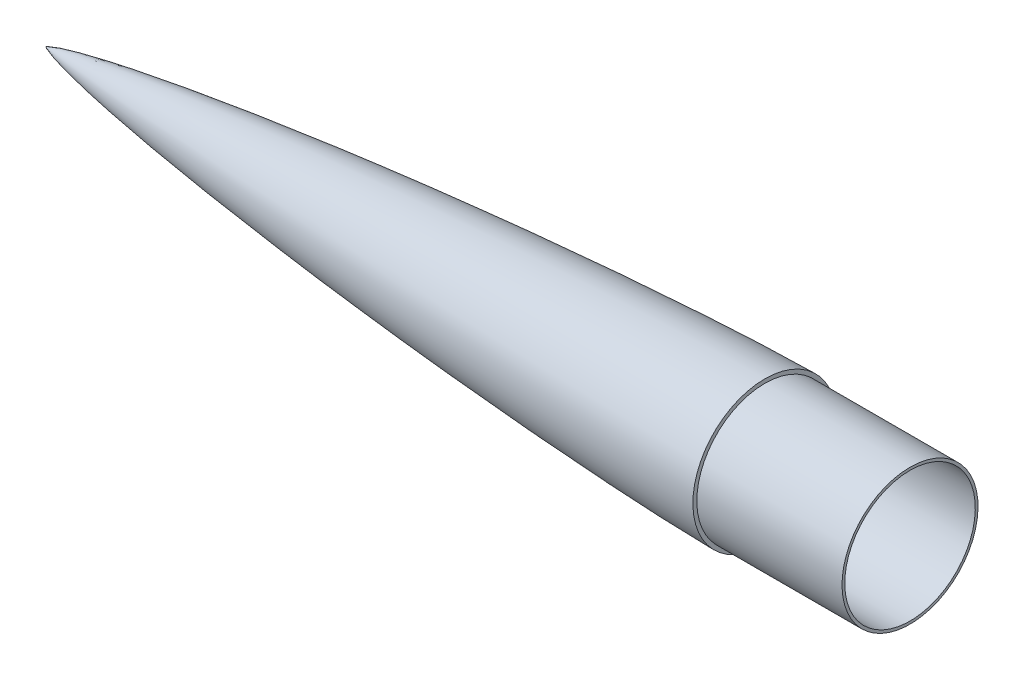
from build123d import *


with BuildPart() as part:
    # Sketch1 → Revolve1 (revolve)
    with BuildSketch(Plane.XY):
        with BuildLine():
            Line((-144.476509098, 35.965), (0, 35.965))
            Line((0, 35.965), (0, 37.465))
            Line((0, 37.465), (-80, 37.465))
            Line((-80, 37.465), (-80, 39.624))
            add(Edge.make_bspline(
                [(-476, 0), (-475.999922921, 0.000860537), (-475.991878272, 0.019203374), (-475.965540019, 0.048886411), (-475.880792524, 0.123460292), (-475.734454888, 0.21905445), (-475.487969376, 0.357045715), (-474.9464108, 0.615798146), (-473.651617124, 1.129793495), (-471.290217835, 1.8875051), (-467.913404676, 2.808553244), (-463.576468666, 3.851264331), (-458.798752951, 4.896132034), (-452.589553113, 6.156031899), (-444.698966637, 7.630967891), (-435.267626096, 9.257539518), (-421.488450856, 11.458403108), (-404.627471312, 13.926156523), (-384.923327778, 16.569178409), (-362.372449265, 19.340500799), (-339.797340005, 21.905895469), (-317.202600234, 24.291785719), (-294.591354976, 26.515336789), (-271.965726929, 28.587274182), (-249.327276754, 30.513862998), (-226.677108608, 32.297557454), (-206.848692738, 33.73236511), (-189.846474353, 34.869230724), (-175.673789139, 35.751629462), (-164.333191827, 36.416922197), (-152.990183207, 37.039475317), (-143.062951853, 37.544363647), (-134.552405593, 37.94633166), (-127.459279754, 38.259174738), (-121.784158279, 38.495377002), (-116.817886196, 38.688950592), (-112.560688712, 38.844722695), (-108.303185392, 38.991911666), (-104.095299496, 39.128269407), (-99.227267658, 39.272405203), (-94.383680396, 39.396692372), (-90.27446724, 39.487225869), (-86.84987531, 39.549302306), (-84.110051575, 39.591747808), (-82.055070818, 39.611951255), (-80.685031997, 39.624), (-80, 39.624)],
                knots=[0, 0, 0, 0, 0, 8.461e-06, 0.000200287, 0.000392112, 0.001132118, 0.001756368, 0.003034211, 0.006409719, 0.015099806, 0.026623021, 0.038146235, 0.051156594, 0.064166953, 0.09018767, 0.118681939, 0.147176208, 0.204164771, 0.26115332, 0.318141952, 0.375130483, 0.432119004, 0.489107555, 0.546096107, 0.603084646, 0.660073112, 0.717061773, 0.745556055, 0.774050337, 0.802544606, 0.831038874, 0.859532974, 0.873780024, 0.888027073, 0.902274269, 0.916521466, 0.923645064, 0.930768662, 0.945015858, 0.958761893, 0.972507929, 0.979380947, 0.986253964, 0.993126982, 1, 1, 1, 1, 1], degree=4))
            Line((-476, 0), (-472.223637938, 0))
            ThreePointArc((-472.223637938, 0), (-309.057037399, 24.42502418), (-144.476509098, 35.965))
        make_face()
    revolve(axis=Axis((-472.223637938, 0, 0), (-1, 0, 0)))


solid = part.part
